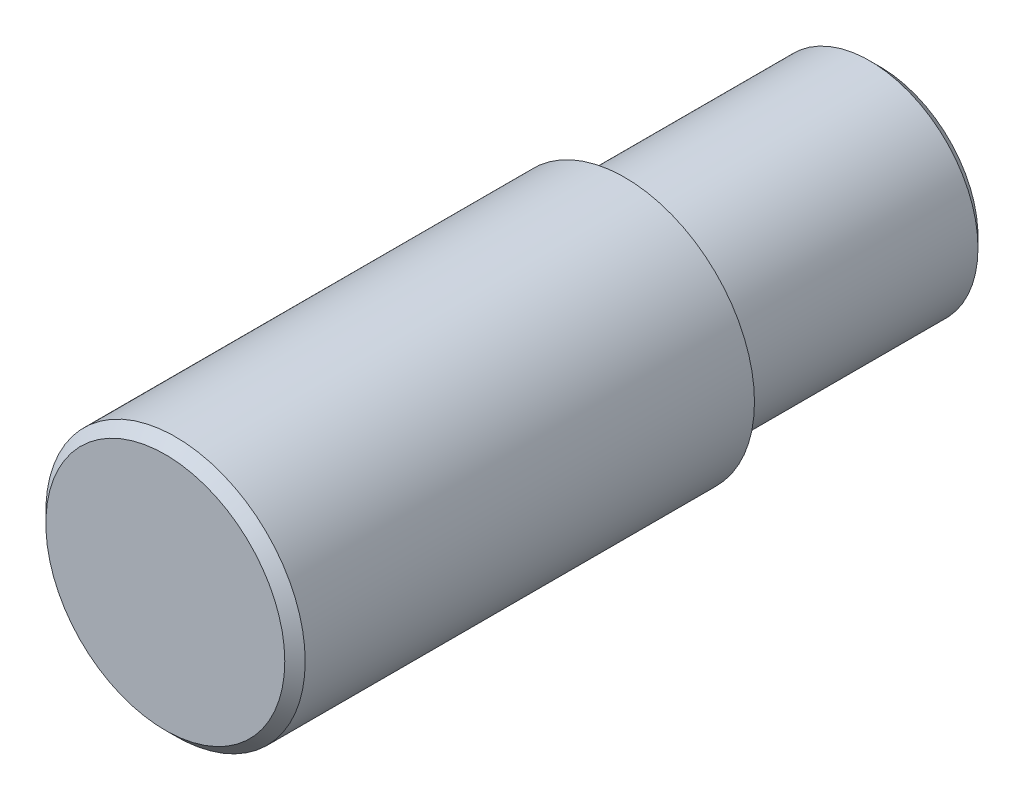
from build123d import *

# Parameters (mm, degrees)
SKETCH1_R           = 12.7
BOSS_EXTRUDE1_DEPTH = 45
SKETCH2_R           = 10.59
BOSS_EXTRUDE2_DEPTH = 25
FILLET1_R           = 1
CHAMFER2_SIZE       = 1
CHAMFER3_SIZE       = 1


with BuildPart() as part:
    # Sketch1 → Boss-Extrude1 (new body)
    with BuildSketch(Plane.XY):
        Circle(SKETCH1_R)
    extrude(amount=BOSS_EXTRUDE1_DEPTH)

    # Sketch2 → Boss-Extrude2 (add)
    with BuildSketch(Plane(origin=(0, 0, 0), x_dir=(-1, 0, 0), z_dir=(0, 0, -1))):
        Circle(SKETCH2_R)
    extrude(amount=BOSS_EXTRUDE2_DEPTH)

    # Fillet1
    fillet1_edges = [part.edges().sort_by_distance(p)[0] for p in [
        (10.59, 0, 0),
    ]]
    fillet(fillet1_edges, radius=FILLET1_R)

    # Chamfer2
    chamfer2_edges = [part.edges().sort_by_distance(p)[0] for p in [
        (10.59, 0, -25),
    ]]
    chamfer(chamfer2_edges, length=CHAMFER2_SIZE)

    # Chamfer3
    chamfer3_edges = [part.edges().sort_by_distance(p)[0] for p in [
        (-12.7, 0, 45),
    ]]
    chamfer(chamfer3_edges, length=CHAMFER3_SIZE)


solid = part.part
